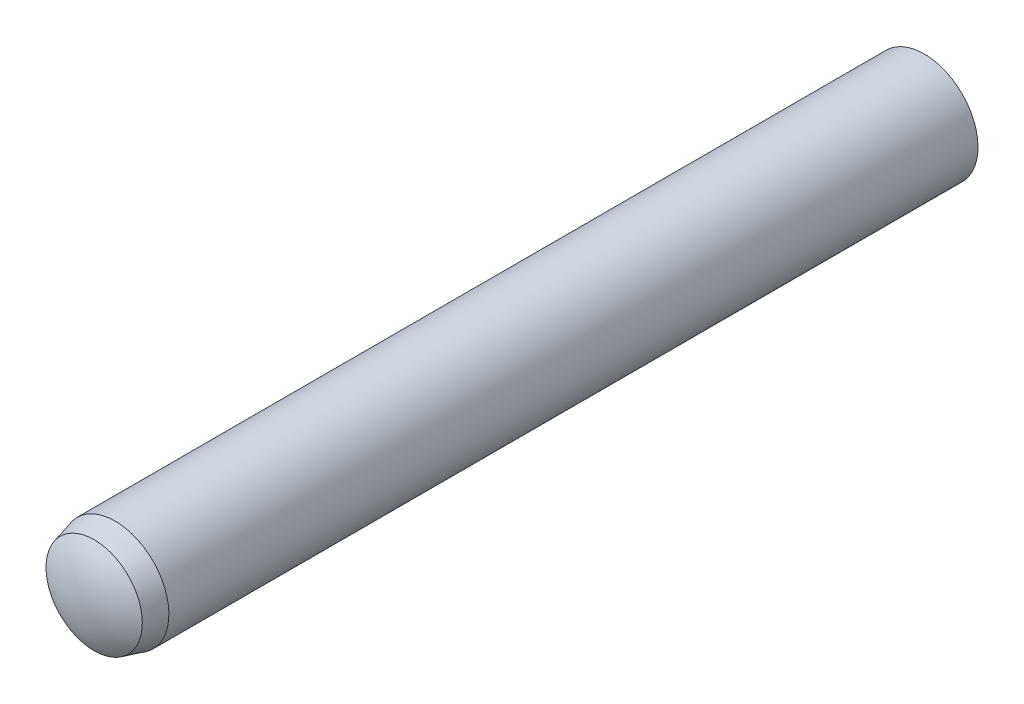
from build123d import *


with BuildPart() as part:
    # Sketch3 → Revolve1 (revolve)
    with BuildSketch(Plane(origin=(0, 0, 0), x_dir=(0, 0, -1), z_dir=(1, 0, 0))):
        with BuildLine():
            Line((-40, 0), (40, 0))
            ThreePointArc((40, 0), (39.616922091, 2.610076627), (38.5, 5))
            Line((38.5, 5), (-36.75, 5))
            Line((-36.75, 5), (-38.7, 4.477499075))
            ThreePointArc((-38.7, 4.477499075), (-39.668425132, 2.331201298), (-40, 0))
        make_face()
    revolve(axis=Axis((0, 0, 40), (0, 0, -1)))


solid = part.part
